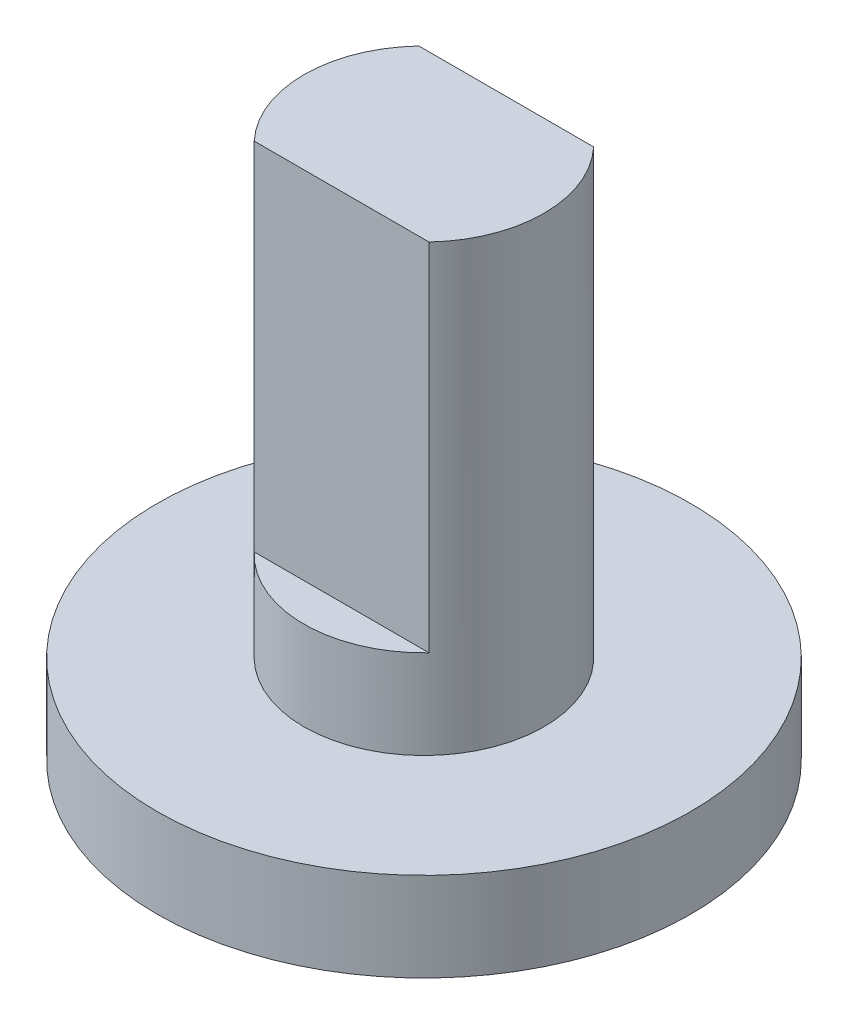
from build123d import *

# Parameters (mm, degrees)
SKETCH1_R           = 6
BOSS_EXTRUDE1_DEPTH = 2
SKETCH2_R           = 2.7
BOSS_EXTRUDE2_DEPTH = 10
CUT_EXTRUDE1_DEPTH  = 8


with BuildPart() as part:
    # Sketch1 → Boss-Extrude1 (new body)
    with BuildSketch(Plane(origin=(0, 0, 0), x_dir=(1, 0, 0), z_dir=(0, 1, 0))):
        Circle(SKETCH1_R)
    extrude(amount=BOSS_EXTRUDE1_DEPTH)

    # Sketch2 → Boss-Extrude2 (add)
    with BuildSketch(Plane(origin=(0, 2, 0), x_dir=(1, 0, 0), z_dir=(0, 1, 0))):
        Circle(SKETCH2_R)
    extrude(amount=BOSS_EXTRUDE2_DEPTH)

    # Sketch3 → Cut-Extrude1 (cut)
    with BuildSketch(Plane(origin=(0, 12, 0), x_dir=(1, 0, 0), z_dir=(0, 1, 0))):
        with BuildLine():
            Line((-1.965, 1.851695169), (1.965, 1.851695169))
            ThreePointArc((1.965, 1.851695169), (0, 2.7), (-1.965, 1.851695169))
        make_face()
        with BuildLine():
            Line((-1.965, -1.851695169), (1.965, -1.851695169))
            ThreePointArc((1.965, -1.851695169), (0, -2.7), (-1.965, -1.851695169))
        make_face()
    extrude(amount=-CUT_EXTRUDE1_DEPTH, mode=Mode.SUBTRACT)


solid = part.part
